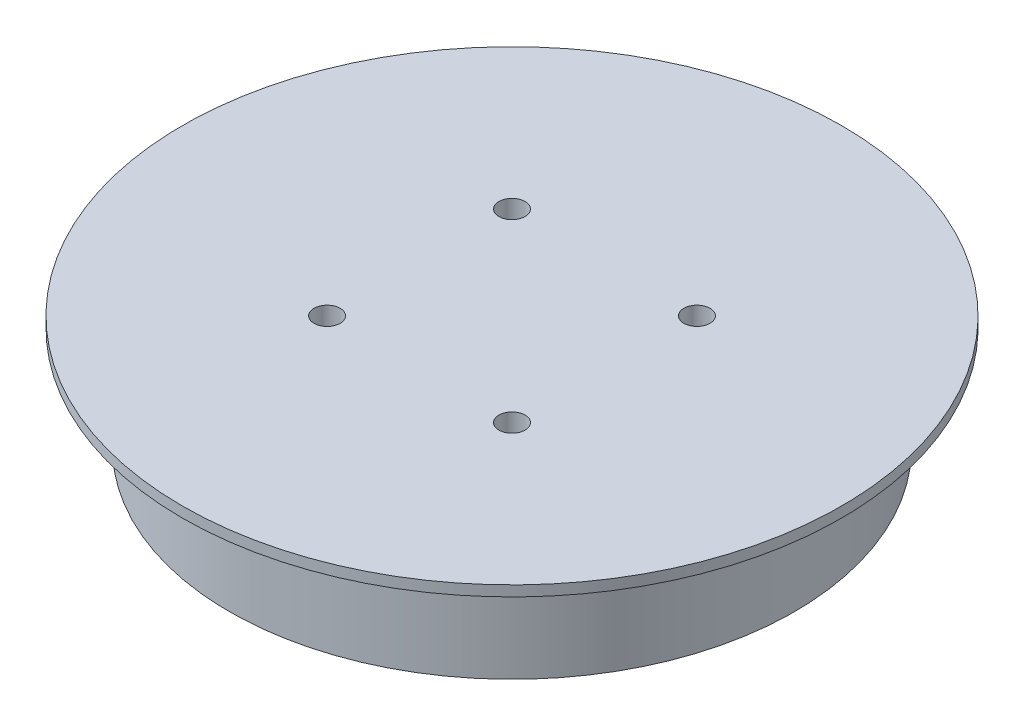
from build123d import *

# Parameters (mm, degrees)
SKETCH1_R                       = 31.5
BOSS_EXTRUDE1_DEPTH             = 11
TAP_DRILL_FOR_M3X0_5_TAP1_D     = 2.5
TAP_DRILL_FOR_M3X0_5_TAP1_DEPTH = 7
TAP_DRILL_FOR_M3X0_5_TAP1_TIP   = 0.751075774
SKETCH9_OUTSIDE_W               = 82.954
SKETCH9_OUTSIDE_H               = 82.954
SKETCH9_OUTSIDE_R               = 27
CUT_EXTRUDE1_DEPTH              = 10


with BuildPart() as part:
    # Sketch1 → Boss-Extrude1 (new body)
    with BuildSketch(Plane(origin=(0, 0, 0), x_dir=(1, 0, 0), z_dir=(0, 1, 0))):
        Circle(SKETCH1_R)
    extrude(amount=BOSS_EXTRUDE1_DEPTH)

    # Tap Drill for M3x0.5 Tap1
    with Locations(Plane(origin=(0, 11, 0), x_dir=(1, 0, 0), z_dir=(0, 1, 0))):
        with Locations((-8.838834765, 8.838834765), (8.838834765, 8.838834765), (8.838834765, -8.838834765), (-8.838834765, -8.838834765)):
            Hole(TAP_DRILL_FOR_M3X0_5_TAP1_D / 2, depth=TAP_DRILL_FOR_M3X0_5_TAP1_DEPTH)
            with Locations((0, 0, -(TAP_DRILL_FOR_M3X0_5_TAP1_DEPTH + TAP_DRILL_FOR_M3X0_5_TAP1_TIP / 2))):  # 118° drill point
                Cone(0, TAP_DRILL_FOR_M3X0_5_TAP1_D / 2, TAP_DRILL_FOR_M3X0_5_TAP1_TIP, mode=Mode.SUBTRACT)

    # Sketch9 outside → Cut-Extrude1 (cut)
    with BuildSketch(Plane.XZ):
        Rectangle(SKETCH9_OUTSIDE_W, SKETCH9_OUTSIDE_H)
        Circle(SKETCH9_OUTSIDE_R, mode=Mode.SUBTRACT)
    extrude(amount=-CUT_EXTRUDE1_DEPTH, mode=Mode.SUBTRACT)


solid = part.part
